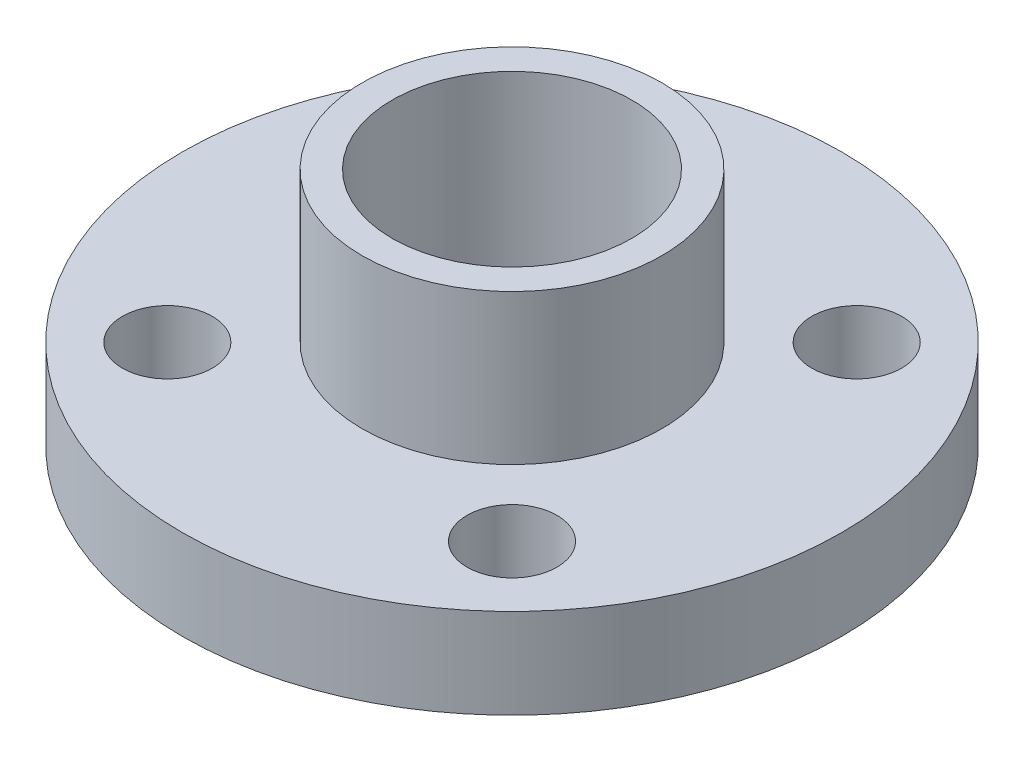
from build123d import *

# Parameters (mm, degrees)
SKETCH1_R                = 11
SKETCH1_R_2              = 5
SKETCH1_R_3              = 1.5
BOSS_EXTRUDE1_DEPTH      = 3
SKETCH2_R                = 5
SKETCH2_R_2              = 4
BOSS_EXTRUDE2_DEPTH      = 8
BOSS_EXTRUDE2_DEPTH_BACK = 2


with BuildPart() as part:
    # Sketch1 → Boss-Extrude1 (new body)
    with BuildSketch(Plane(origin=(0, 0, 0), x_dir=(1, 0, 0), z_dir=(0, 1, 0))):
        Circle(SKETCH1_R)
        Circle(SKETCH1_R_2, mode=Mode.SUBTRACT)
        with Locations((-5.75, 5.75)):
            Circle(SKETCH1_R_3, mode=Mode.SUBTRACT)
        with Locations((5.75, 5.75)):
            Circle(SKETCH1_R_3, mode=Mode.SUBTRACT)
        with Locations((5.75, -5.75)):
            Circle(SKETCH1_R_3, mode=Mode.SUBTRACT)
        with Locations((-5.75, -5.75)):
            Circle(SKETCH1_R_3, mode=Mode.SUBTRACT)
    extrude(amount=BOSS_EXTRUDE1_DEPTH)

    # Sketch2 → Boss-Extrude2 (add, two sides)
    with BuildSketch(Plane(origin=(0, 0, 0), x_dir=(1, 0, 0), z_dir=(0, 1, 0))) as boss_extrude2_sk:
        Circle(SKETCH2_R)
        Circle(SKETCH2_R_2, mode=Mode.SUBTRACT)
    extrude(amount=BOSS_EXTRUDE2_DEPTH)
    extrude(boss_extrude2_sk.sketch, amount=-BOSS_EXTRUDE2_DEPTH_BACK)


solid = part.part
